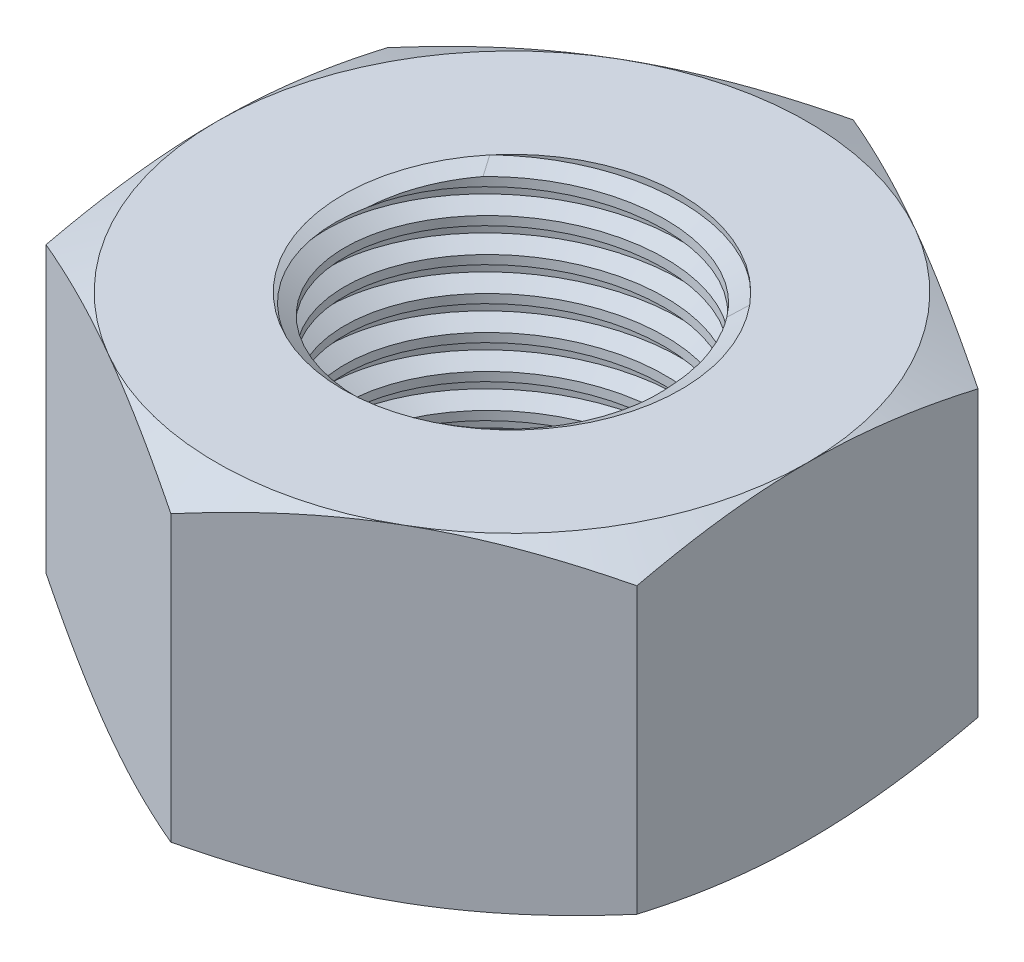
from build123d import *

# Parameters (mm, degrees)
EXTRUDE1_DEPTH      = 12.303125
SKETCH2_W           = 6.35
SKETCH2_H           = 12.303125
LPATTERN1_COUNT     = 10
LPATTERN1_PITCH     = 1.27
LPATTERN1_COL_COUNT = 2
LPATTERN1_COL_PITCH = 1.27


with BuildPart() as part:
    # Sketch1 → Extrude1 (new body)
    with BuildSketch(Plane(origin=(0, 0, 0), x_dir=(1, 0, 0), z_dir=(0, 1, 0))):
        Polygon((0, 12.831609733), (-11.1125, 6.415804866), (-11.1125, -6.415804866), (0, -12.831609733), (11.1125, -6.415804866), (11.1125, 6.415804866), align=None)
    extrude(amount=EXTRUDE1_DEPTH)

    # Sketch4 → Cut-Revolve2 (revolve, cut)
    with BuildSketch(Plane(origin=(0, 0, 0), x_dir=(0, 0, -1), z_dir=(1, 0, 0)), mode=Mode.PRIVATE) as cut_revolve2_sk:
        Polygon((0, 12.303125), (6.35, 12.303125), (5.721290563, 12.009952975), (5.721290563, 0.293172025), (6.35, 0), (0, 0), align=None)
    revolve(cut_revolve2_sk.sketch.rotate(Axis((0, 12.303125, 0), (0, 1, 0)), 54.6652943), axis=Axis((0, 12.303125, 0), (0, 1, 0)), mode=Mode.SUBTRACT)  # turned: the seam where the file's is


with BuildPart() as body_2:
    # Sketch2 → Revolve1 (revolve)
    with BuildSketch(Plane(origin=(0, 0, 0), x_dir=(0, 0, -1), z_dir=(1, 0, 0))):
        with Locations((3.175, 6.1515625)):
            Rectangle(SKETCH2_W, SKETCH2_H)
    revolve(axis=Axis((0, -6.35, 0), (0, 1, 0)))

    # Sketch3 → Cut-Revolve1 (revolve, cut)
    with BuildSketch(Plane(origin=(0, 0, 0), x_dir=(0, 0, -1), z_dir=(1, 0, 0))):
        Polygon((-6.365796215, 12.145162846), (-6.476369723, 11.039427768), (-5.752882994, 11.365933534), (-5.721290563, 11.681857842), align=None)
    cut_revolve1 = revolve(axis=Axis((0, 12.303125, -0.135293799), (0, -0.99503719, 0.099503719)), mode=Mode.SUBTRACT)

    # LPattern1: Cut-Revolve1 ×10
    with Locations(*[(0, -i * LPATTERN1_PITCH, 0) for i in range(1, LPATTERN1_COUNT)]):
        add(cut_revolve1, mode=Mode.SUBTRACT)

    # LPattern1 col: Cut-Revolve1 ×2
    with Locations(*[(0, i * LPATTERN1_COL_PITCH, 0) for i in range(1, LPATTERN1_COL_COUNT)]):
        add(cut_revolve1, mode=Mode.SUBTRACT)


with BuildPart() as part_1:
    add(part.part)

    # Combine1: cut body 2
    add(body_2.part, mode=Mode.SUBTRACT)

    # Sketch5 → Cut-Revolve3 (revolve, cut)
    with BuildSketch(Plane(origin=(0, 0, 0), x_dir=(0, 0, -1), z_dir=(1, 0, 0)), mode=Mode.PRIVATE) as cut_revolve3_sk:
        Polygon((0, 0), (11.1125, 0), (12.831609733, 0.801634034), (12.831609733, 11.501490966), (11.1125, 12.303125), (0, 12.303125), (0, 13.573125), (14.101609733, 13.573125), (14.101609733, -1.27), (0, -1.27), align=None)
    revolve(cut_revolve3_sk.sketch.rotate(Axis((0, 0, 0), (0, 1, 0)), 54.6652943), axis=Axis((0, 0, 0), (0, 1, 0)), mode=Mode.SUBTRACT)  # turned: the seam where the file's is


solid = part_1.part
